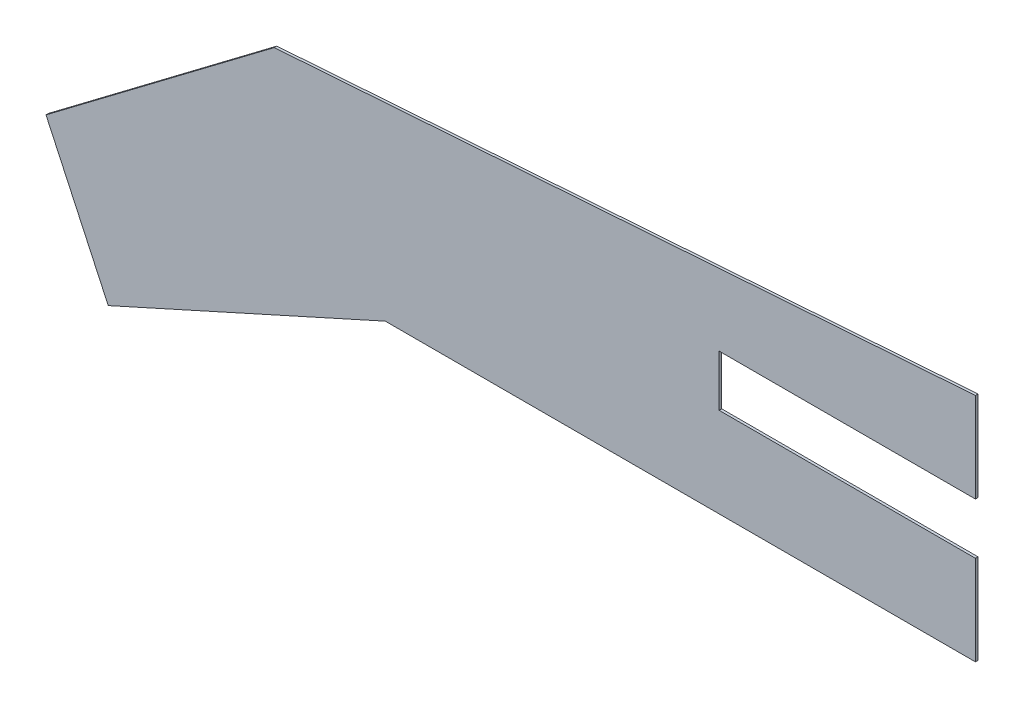
from build123d import *

# Parameters (mm, degrees)
SALIENTE_EXTRUIR1_DEPTH = 0.1


with BuildPart() as part:
    # Model → Saliente-Extruir1 (new body)
    with BuildSketch(Plane.XY):
        Polygon((62.548169037, 19.431931443), (62.548169037, 15.931931443), (51.538777187, 15.931931443), (39.529385336, 15.931931443), (28.72267281, 11.05475975), (26.295087671, 16.283445098), (35.196841696, 23.007071539), (62.548169037, 24.931931443), (62.548169037, 21.431931443), (52.548169037, 21.431931443), (52.548169037, 19.431931443), align=None)
    extrude(amount=SALIENTE_EXTRUIR1_DEPTH)


solid = part.part
